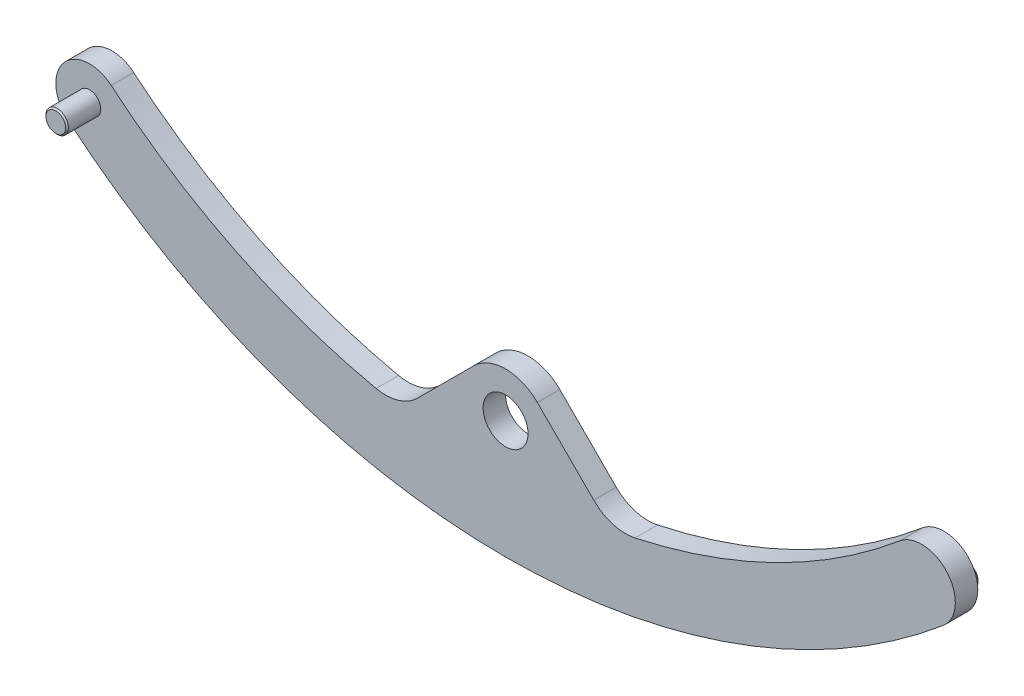
from build123d import *

# Parameters (mm, degrees)
SKETCH1_R           = 4
BOSS_EXTRUDE1_DEPTH = 4
SKETCH2_R           = 2
BOSS_EXTRUDE2_DEPTH = 6
CHAMFER1_SIZE       = 0.25
SKETCH3_R           = 2
BOSS_EXTRUDE3_DEPTH = 3
CHAMFER2_SIZE       = 0.25
FILLET2_R           = 8


with BuildPart() as part:
    # Sketch1 → Boss-Extrude1 (new body)
    with BuildSketch(Plane.XY):
        with BuildLine():
            ThreePointArc((5.656854249, 5.656854249), (0, 8), (-5.656854249, 5.656854249))
            Line((-5.656854249, 5.656854249), (-18.697995031, -7.384286532))
            ThreePointArc((-18.697995031, -7.384286532), (-46.023235671, 1.192804635), (-70.171144566, 16.591303421))
            ThreePointArc((-70.171144566, 16.591303421), (-78.62508069, 15.86263065), (-77.896407918, 7.408694525))
            ThreePointArc((-77.896407918, 7.408694525), (0, -21), (77.896407918, 7.408694525))
            ThreePointArc((77.896407918, 7.408694525), (78.62508069, 15.86263065), (70.171144566, 16.591303421))
            ThreePointArc((70.171144566, 16.591303421), (46.023235671, 1.192804635), (18.697995031, -7.384286532))
            Line((18.697995031, -7.384286532), (5.656854249, 5.656854249))
        make_face()
        Circle(SKETCH1_R, mode=Mode.SUBTRACT)
    extrude(amount=BOSS_EXTRUDE1_DEPTH)

    # Sketch2 → Boss-Extrude2 (add)
    with BuildSketch(Plane.XY.offset(4)):
        with Locations((-74.033776242, 11.999998973)):
            Circle(SKETCH2_R)
    extrude(amount=BOSS_EXTRUDE2_DEPTH)

    # Chamfer1
    chamfer1_edges = [part.edges().sort_by_distance(p)[0] for p in [
        (-76.033776242, 11.999998973, 10),
    ]]
    chamfer(chamfer1_edges, length=CHAMFER1_SIZE)

    # Sketch3 → Boss-Extrude3 (add)
    with BuildSketch(Plane(origin=(0, 0, 0), x_dir=(-1, 0, 0), z_dir=(0, 0, -1))):
        with Locations((-75.321320134, 10.469564157)):
            Circle(SKETCH3_R)
    extrude(amount=BOSS_EXTRUDE3_DEPTH)

    # Chamfer2
    chamfer2_edges = [part.edges().sort_by_distance(p)[0] for p in [
        (77.321320134, 10.469564157, -3),
    ]]
    chamfer(chamfer2_edges, length=CHAMFER2_SIZE)

    # Fillet2
    fillet2_edges = [part.edges().sort_by_distance(p)[0] for p in [
        (18.697995031, -7.384286532, 2),
        (-18.697995031, -7.384286532, 2),
    ]]
    fillet(fillet2_edges, radius=FILLET2_R)


solid = part.part
